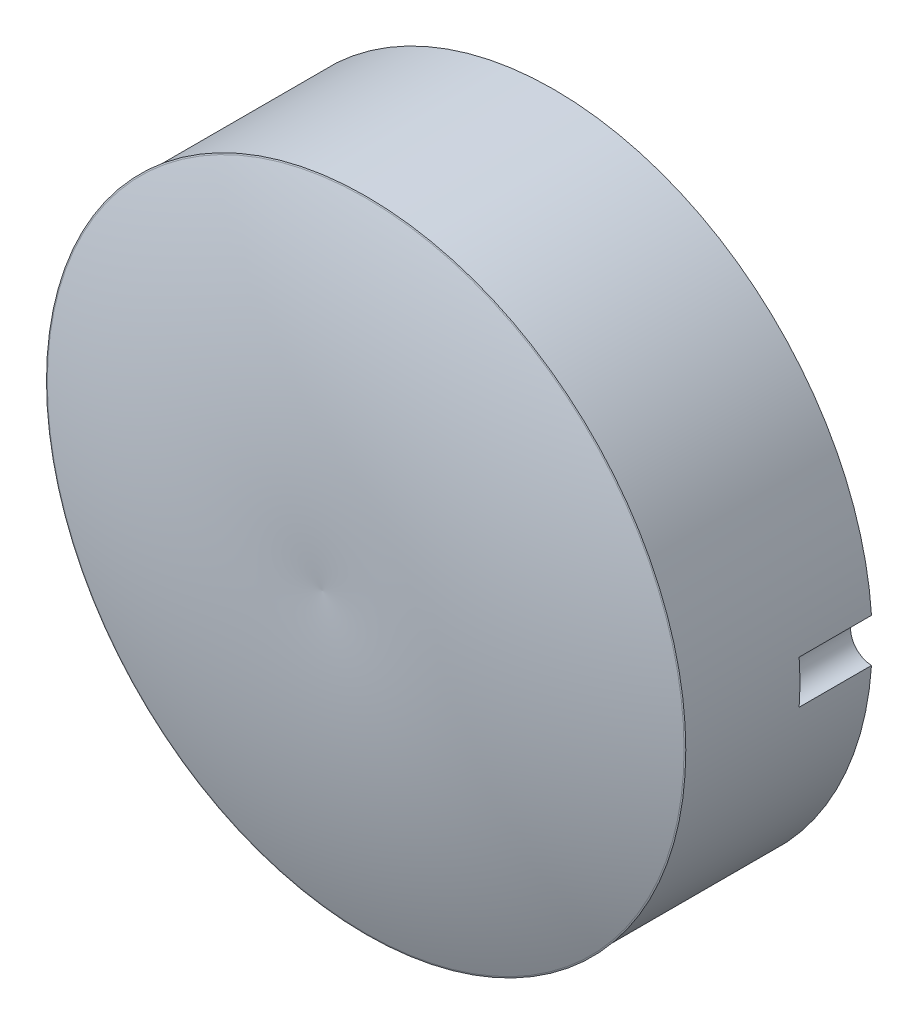
from build123d import *

# Parameters (mm, degrees)
SKETCH1_R           = 22
BOSS_EXTRUDE1_DEPTH = 13
SKETCH4_R           = 1.5
CUT_EXTRUDE1_DEPTH  = 5


with BuildPart() as part:
    # Sketch1 → Boss-Extrude1 (new body)
    with BuildSketch(Plane.XY):
        Circle(SKETCH1_R)
    extrude(amount=BOSS_EXTRUDE1_DEPTH)

    # Sketch3 → Revolve2 (revolve)
    with BuildSketch(Plane(origin=(0, 0, 0), x_dir=(1, 0, 0), z_dir=(0, 1, 0)), mode=Mode.PRIVATE) as revolve2_sk:
        with BuildLine():
            Line((0, -13), (0, -16))
            ThreePointArc((0, -16), (11.162153259, -15.689123897), (22, -13))
            Line((22, -13), (22.086787967, -12.969993282))
            Line((22.086787967, -12.969993282), (0, -13))
        make_face()
    revolve(revolve2_sk.sketch.rotate(Axis((0, 0, 0), (0, 0, 1)), 180), axis=Axis((0, 0, 0), (0, 0, 1)))  # turned: the seam where the file's is

    # Sketch4 → Cut-Extrude1 (cut)
    with BuildSketch(Plane(origin=(0, 0, 0), x_dir=(-1, 0, 0), z_dir=(0, 0, -1))):
        with Locations((-22, 0)):
            Circle(SKETCH4_R)
    extrude(amount=-CUT_EXTRUDE1_DEPTH, mode=Mode.SUBTRACT)


solid = part.part
